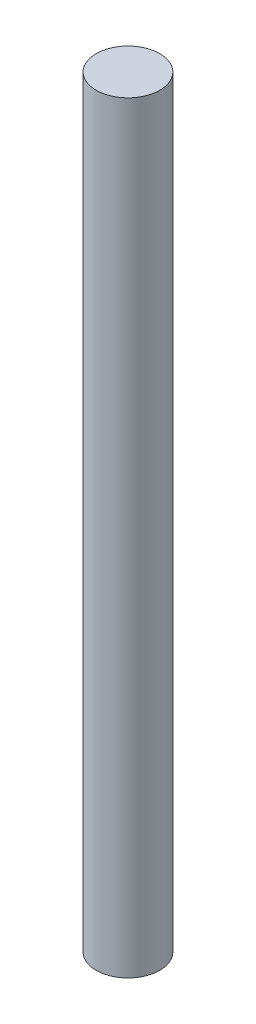
from build123d import *

# Parameters (mm, degrees)
SKETCH1_R           = 6.35
BOSS_EXTRUDE1_DEPTH = 152.4


with BuildPart() as part:
    # Sketch1 → Boss-Extrude1 (new body)
    with BuildSketch(Plane(origin=(0, 0, 0), x_dir=(1, 0, 0), z_dir=(0, 1, 0))):
        Circle(SKETCH1_R)
    extrude(amount=BOSS_EXTRUDE1_DEPTH)


solid = part.part
